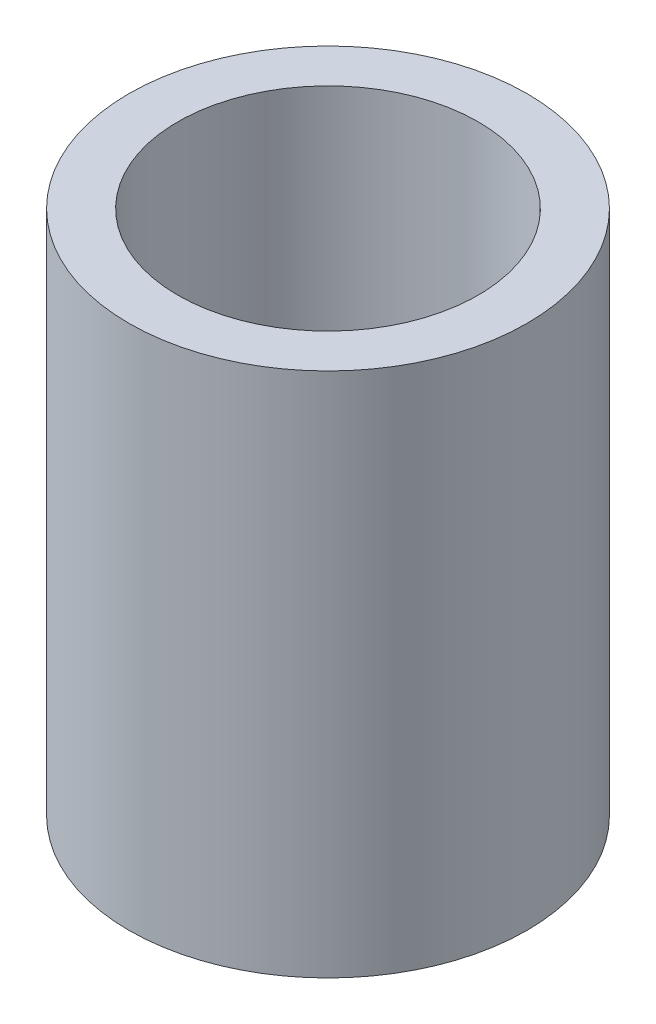
from build123d import *

# Parameters (mm, degrees)
SKETCH1_R           = 13.25
BOSS_EXTRUDE1_DEPTH = 35
SKETCH7_R           = 10
CUT_EXTRUDE4_DEPTH  = 8
SKETCH10_R          = 3.485
BOSS_EXTRUDE3_DEPTH = 4
SKETCH11_R          = 1.625
CUT_EXTRUDE5_DEPTH  = 8.75
SKETCH13_R          = 10
CUT_EXTRUDE6_DEPTH  = 18


with BuildPart() as part:
    # Sketch1 → Boss-Extrude1 (new body)
    with BuildSketch(Plane(origin=(0, 0, 0), x_dir=(1, 0, 0), z_dir=(0, 1, 0))):
        Circle(SKETCH1_R)
    extrude(amount=BOSS_EXTRUDE1_DEPTH)

    # Sketch7 → Cut-Extrude4 (cut)
    with BuildSketch(Plane.XZ):
        Circle(SKETCH7_R)
    extrude(amount=-CUT_EXTRUDE4_DEPTH, mode=Mode.SUBTRACT)

    # Sketch10 → Boss-Extrude3 (add)
    with BuildSketch(Plane.XZ.offset(-8)):
        Circle(SKETCH10_R)
    extrude(amount=BOSS_EXTRUDE3_DEPTH)

    # Sketch11 → Cut-Extrude5 (cut)
    with BuildSketch(Plane.XZ.offset(-4)):
        Circle(SKETCH11_R)
    extrude(amount=-CUT_EXTRUDE5_DEPTH, mode=Mode.SUBTRACT)

    # Sketch13 → Cut-Extrude6 (cut)
    with BuildSketch(Plane(origin=(0, 35, 0), x_dir=(1, 0, 0), z_dir=(0, 1, 0))):
        Circle(SKETCH13_R)
    extrude(amount=-CUT_EXTRUDE6_DEPTH, mode=Mode.SUBTRACT)


solid = part.part
